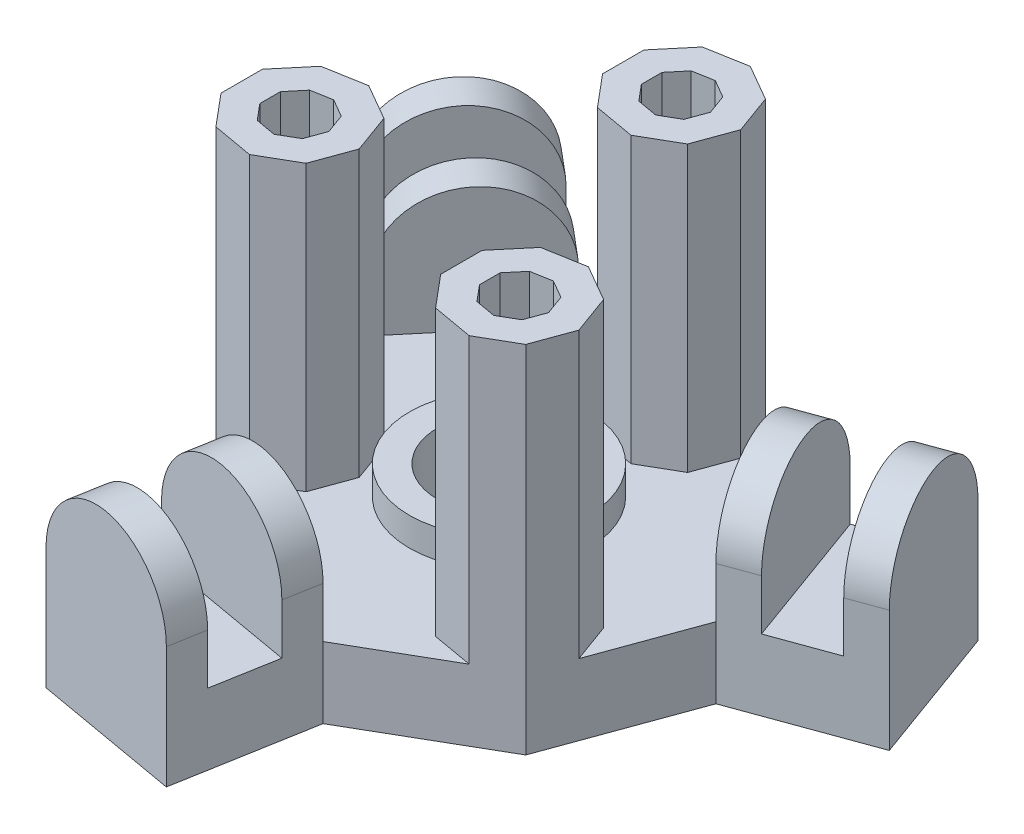
from build123d import *

# Parameters (mm, degrees)
SKETCH1_R            = 5.5
BOSS_EXTRUDE1_DEPTH  = 6.35
BOSS_EXTRUDE2_DEPTH  = 3.18
BOSS_EXTRUDE4_DEPTH  = 3.175
BOSS_EXTRUDE5_DEPTH  = 3.175
BOSS_EXTRUDE6_DEPTH  = 3.175
BOSS_EXTRUDE7_DEPTH  = 3.175
BOSS_EXTRUDE8_DEPTH  = 3.175
BOSS_EXTRUDE9_DEPTH  = 25.4
SKETCH15_R           = 8
SKETCH15_R_2         = 5.5
BOSS_EXTRUDE10_DEPTH = 2.54


with BuildPart() as part:
    # Sketch1 → Boss-Extrude1 (new body)
    with BuildSketch(Plane(origin=(0, 0, 0), x_dir=(1, 0, 0), z_dir=(0, 1, 0))):
        Polygon((1.265828837, -30.968710893), (-11.781412955, -28.668130141), (-9.68401773, -16.773210729), (3.363224062, -19.073791481), align=None)
        Polygon((-9.68401773, -16.773210729), (3.363224062, -19.073791481), (14.836775938, -12.449533217), (19.368035459, 0), (14.836775938, 12.449533217), (3.363224062, 19.073791481), (-9.68401773, 16.773210729), (-18.2, 6.624258264), (-18.2, -6.624258264), align=None)
        Circle(SKETCH1_R, mode=Mode.SUBTRACT)
        Polygon((26.186775938, 16.580595376), (30.718035459, 4.131062159), (19.368035459, 0), (14.836775938, 12.449533217), align=None)
        Polygon((-27.452604774, 14.388115517), (-18.936622504, 24.537067982), (-9.68401773, 16.773210729), (-18.2, 6.624258264), align=None)
    extrude(amount=BOSS_EXTRUDE1_DEPTH)

    # Sketch4 → Boss-Extrude2 (add)
    with BuildSketch(Plane(origin=(-5.257792059, 0, 29.818420517), x_dir=(-0.984807753, 0, -0.173648178), z_dir=(0.173648178, 0, -0.984807753))):
        with BuildLine():
            Line((-6.624258264, 6.35), (-6.624258264, 10.84999989))
            ThreePointArc((-6.624258264, 10.84999989), (0, 17.474258154), (6.624258264, 10.84999989))
            Line((6.624258264, 10.84999989), (6.624258264, 6.35))
            Line((6.624258264, 6.35), (-6.624258264, 6.35))
        make_face()
    extrude(amount=BOSS_EXTRUDE2_DEPTH)

    # Sketch6 → Boss-Extrude4 (add)
    with BuildSketch(Plane(origin=(-3.160396834, 0, 17.923501105), x_dir=(-0.984807753, 0, -0.173648178), z_dir=(0.173648178, 0, -0.984807753))):
        with BuildLine():
            Line((-6.624258264, 6.35), (-6.624258264, 10.85))
            ThreePointArc((-6.624258264, 10.85), (0, 17.474258264), (6.624258264, 10.85))
            Line((6.624258264, 10.85), (6.624258264, 6.35))
            Line((6.624258264, 6.35), (-6.624258264, 6.35))
        make_face()
    extrude(amount=-BOSS_EXTRUDE4_DEPTH)

    # Sketch8 → Boss-Extrude5 (add)
    with BuildSketch(Plane(origin=(28.452405698, 0, -10.355828767), x_dir=(0.342020143, 0, 0.939692621), z_dir=(-0.939692621, 0, 0.342020143))):
        with BuildLine():
            Line((-6.624258264, 10.85), (-6.624258264, 6.35))
            Line((-6.624258264, 6.35), (6.624258264, 6.35))
            Line((6.624258264, 6.35), (6.624258264, 10.85))
            ThreePointArc((6.624258264, 10.85), (0, 17.474258264), (-6.624258264, 10.85))
        make_face()
    extrude(amount=BOSS_EXTRUDE5_DEPTH)

    # Sketch9 → Boss-Extrude6 (add)
    with BuildSketch(Plane(origin=(17.102405698, 0, -6.224766609), x_dir=(0.342020143, 0, 0.939692621), z_dir=(-0.939692621, 0, 0.342020143))):
        with BuildLine():
            Line((-6.624258264, 6.35), (-6.624258264, 10.85))
            ThreePointArc((-6.624258264, 10.85), (0, 17.474258264), (6.624258264, 10.85))
            Line((6.624258264, 10.85), (6.624258264, 6.35))
            Line((6.624258264, 6.35), (-6.624258264, 6.35))
        make_face()
    extrude(amount=-BOSS_EXTRUDE6_DEPTH)

    # Sketch10 → Boss-Extrude7 (add)
    with BuildSketch(Plane(origin=(-23.194613639, 0, -19.46259175), x_dir=(0.64278761, 0, -0.766044443), z_dir=(0.766044443, 0, 0.64278761))):
        with BuildLine():
            Line((-6.624258264, 10.85), (-6.624258264, 6.35))
            Line((-6.624258264, 6.35), (6.624258264, 6.35))
            Line((6.624258264, 6.35), (6.624258264, 10.85))
            ThreePointArc((6.624258264, 10.85), (0, 17.474258264), (-6.624258264, 10.85))
        make_face()
    extrude(amount=BOSS_EXTRUDE7_DEPTH)

    # Sketch11 → Boss-Extrude8 (add)
    with BuildSketch(Plane(origin=(-13.942008865, 0, -11.698734496), x_dir=(0.64278761, 0, -0.766044443), z_dir=(0.766044443, 0, 0.64278761))):
        with BuildLine():
            Line((-6.624258264, 10.85), (-6.624258264, 6.35))
            Line((-6.624258264, 6.35), (6.624258264, 6.35))
            Line((6.624258264, 6.35), (6.624258264, 10.85))
            ThreePointArc((6.624258264, 10.85), (0, 17.474258264), (-6.624258264, 10.85))
        make_face()
    extrude(amount=-BOSS_EXTRUDE8_DEPTH)

    # Sketch12 → Boss-Extrude9 (add)
    with BuildSketch(Plane(origin=(0, 6.35, 0), x_dir=(1, 0, 0), z_dir=(0, 1, 0))):
        Polygon((14.836775938, -12.449533217), (16.101545079, -8.974608561), (14.836775938, -5.499683905), (11.634268052, -3.650715115), (7.992510452, -4.292855237), (5.615521995, -7.125639771), (5.615521995, -10.823577351), (7.992510452, -13.656361885), (11.634268052, -14.298502007), align=None)
        Polygon((12.766148966, -10.712070889), (13.398533537, -8.974608561), (12.766148966, -7.237146233), (11.164895023, -6.312661838), (9.344016223, -6.633731899), (8.155521995, -8.050124166), (8.155521995, -9.899092956), (9.344016223, -11.315485223), (11.164895023, -11.636555284), align=None, mode=Mode.SUBTRACT)
        Polygon((6.565731948, 10.274973378), (7.83050109, 13.749898034), (6.565731948, 17.224822691), (3.363224062, 19.073791481), (-0.278533537, 18.431651359), (-2.655521995, 15.598866825), (-2.655521995, 11.900929244), (-0.278533537, 9.06814471), (3.363224062, 8.426004588), align=None)
        Polygon((-0.115521995, 12.825413639), (1.072972234, 11.409021372), (2.893851034, 11.087951311), (4.495104977, 12.012435706), (5.127489548, 13.749898034), (4.495104977, 15.487360363), (2.893851034, 16.411844758), (1.072972234, 16.090774697), (-0.115521995, 14.674382429), align=None, mode=Mode.SUBTRACT)
        Polygon((-18.2, -6.624258264), (-15.823011542, -9.457042798), (-12.181253943, -10.09918292), (-8.978746057, -8.25021413), (-7.713976916, -4.775289474), (-8.978746057, -1.300364817), (-12.181253943, 0.548603973), (-15.823011542, -0.093536149), (-18.2, -2.926320684), align=None)
        Polygon((-11.049373028, -6.512751802), (-10.416988458, -4.775289474), (-11.049373028, -3.037827145), (-12.650626972, -2.11334275), (-14.471505771, -2.434412811), (-15.66, -3.850805079), (-15.66, -5.699773869), (-14.471505771, -7.116166136), (-12.650626972, -7.437236197), align=None, mode=Mode.SUBTRACT)
    extrude(amount=BOSS_EXTRUDE9_DEPTH)

    # Sketch15 → Boss-Extrude10 (add)
    with BuildSketch(Plane(origin=(0, 6.35, 0), x_dir=(1, 0, 0), z_dir=(0, 1, 0))):
        Circle(SKETCH15_R)
        Circle(SKETCH15_R_2, mode=Mode.SUBTRACT)
    extrude(amount=BOSS_EXTRUDE10_DEPTH)


solid = part.part
